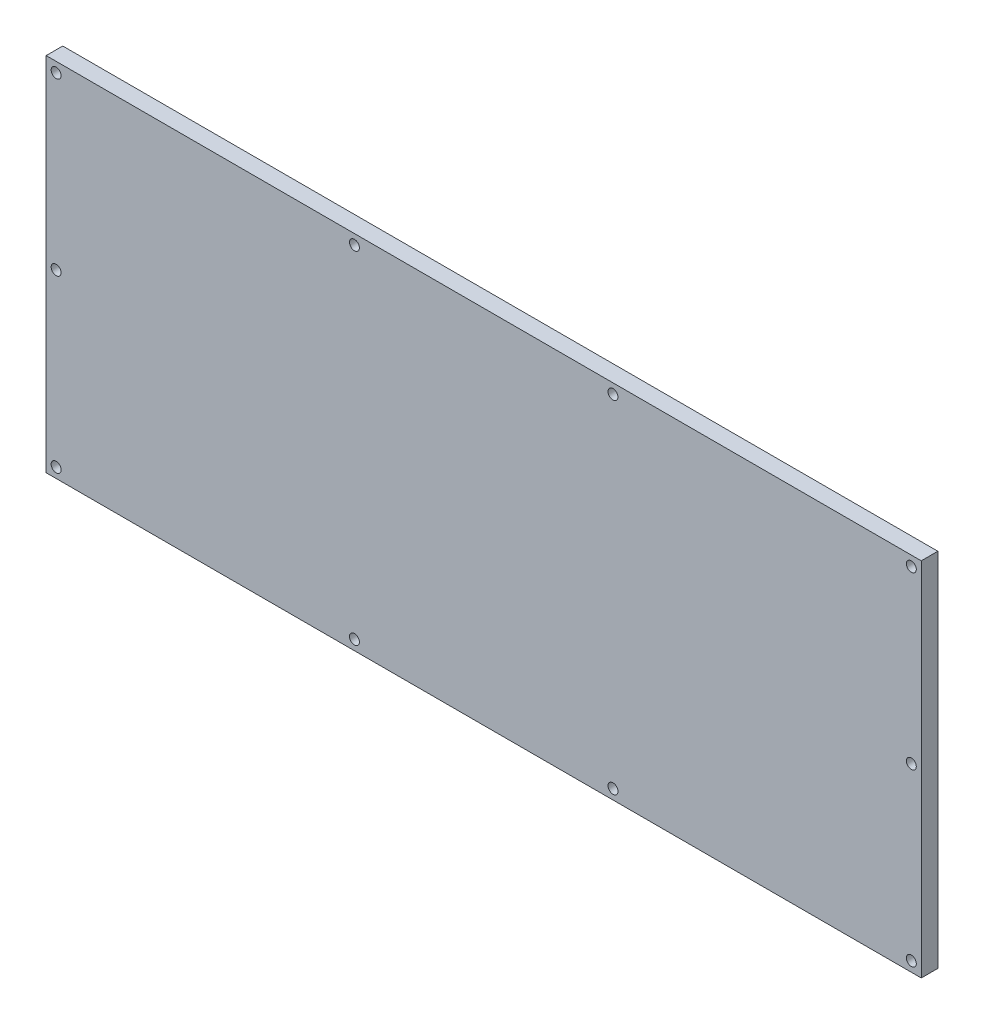
from build123d import *

# Parameters (mm, degrees)
SKETCH1_W                 = 264
SKETCH1_H                 = 109
BOSS_EXTRUDE1_DEPTH       = 5
CUT_EXTRUDE1_DEPTH        = 1
CUT_EXTRUDE2_DEPTH        = 4
FILLET1_R                 = 3
F_3_0MM_DOWEL_HOLE1_D     = 3
F_3_0MM_DOWEL_HOLE1_DEPTH = 15
F_3_0MM_DOWEL_HOLE1_TIP   = 0.901290929


with BuildPart() as part:
    # Sketch1 → Boss-Extrude1 (new body)
    with BuildSketch(Plane.XY):
        Rectangle(SKETCH1_W, SKETCH1_H)
    extrude(amount=BOSS_EXTRUDE1_DEPTH)

    # Sketch2 → Cut-Extrude1 (cut)
    with BuildSketch(Plane(origin=(0, 0, 0), x_dir=(-1, 0, 0), z_dir=(0, 0, -1))):
        with BuildLine():
            Line((121, 49.5), (-121, 49.5))
            ThreePointArc((-121, 49.5), (-125.242640687, 47.742640687), (-127, 43.5))
            Line((-127, 43.5), (-127, -43.5))
            ThreePointArc((-127, -43.5), (-125.242640687, -47.742640687), (-121, -49.5))
            Line((-121, -49.5), (121, -49.5))
            ThreePointArc((121, -49.5), (125.242640687, -47.742640687), (127, -43.5))
            Line((127, -43.5), (127, 43.5))
            ThreePointArc((127, 43.5), (125.242640687, 47.742640687), (121, 49.5))
        make_face()
        with BuildLine():
            Line((121, 47.5), (-121, 47.5))
            ThreePointArc((-121, 47.5), (-123.828427125, 46.328427125), (-125, 43.5))
            Line((-125, 43.5), (-125, -43.5))
            ThreePointArc((-125, -43.5), (-123.828427125, -46.328427125), (-121, -47.5))
            Line((-121, -47.5), (121, -47.5))
            ThreePointArc((121, -47.5), (123.828427125, -46.328427125), (125, -43.5))
            Line((125, -43.5), (125, 43.5))
            ThreePointArc((125, 43.5), (123.828427125, 46.328427125), (121, 47.5))
        make_face(mode=Mode.SUBTRACT)
    extrude(amount=-CUT_EXTRUDE1_DEPTH, mode=Mode.SUBTRACT)

    # Sketch3 → Cut-Extrude2 (cut)
    with BuildSketch(Plane(origin=(0, 0, 0), x_dir=(-1, 0, 0), z_dir=(0, 0, -1))):
        Polygon((-117, 39.5), (-117, -37.249488302), (115.898875272, 39.5), align=None)
        Polygon((-91.878678072, -39.5), (117, 29.333873245), (117, -39.5), align=None)
    extrude(amount=-CUT_EXTRUDE2_DEPTH, mode=Mode.SUBTRACT)

    # Fillet1
    fillet1_edges = [part.edges().sort_by_distance(p)[0] for p in [
        (117, 39.5, 2),
        (-115.898875272, 39.5, 2),
        (117, -37.249488302, 2),
        (-117, -39.5, 2),
        (91.878678072, -39.5, 2),
        (-117, 29.333873245, 2),
    ]]
    fillet(fillet1_edges, radius=FILLET1_R)

    # Ø3.0mm Dowel Hole1
    with Locations(Plane(origin=(0, 0, 0), x_dir=(-1, 0, 0), z_dir=(0, 0, -1))):
        with Locations((-129, -51.5), (-129, 51.5), (129, 51.5), (129, -51.5), (-39, -51.5), (39, -51.5), (39, 51.5), (-39, 51.5), (129, 0), (-129, 0)):
            Hole(F_3_0MM_DOWEL_HOLE1_D / 2, depth=F_3_0MM_DOWEL_HOLE1_DEPTH)
            with Locations((0, 0, -(F_3_0MM_DOWEL_HOLE1_DEPTH + F_3_0MM_DOWEL_HOLE1_TIP / 2))):  # 118° drill point
                Cone(0, F_3_0MM_DOWEL_HOLE1_D / 2, F_3_0MM_DOWEL_HOLE1_TIP, mode=Mode.SUBTRACT)


solid = part.part
